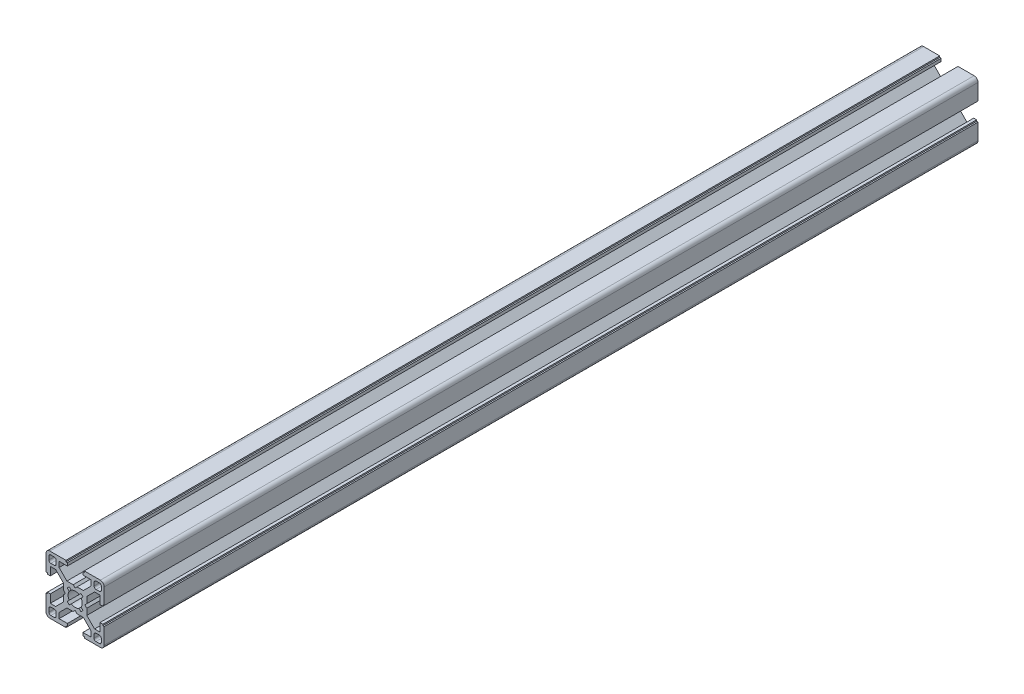
from build123d import *

# Parameters (mm, degrees)
ESTRUSIONE_ESTRUSIONE2_DEPTH = 450


with BuildPart() as part:
    # Schizzo1 → Estrusione-Estrusione2 (new body)
    with BuildSketch(Plane.XY):
        with BuildLine():
            Line((-15, 13), (-15, 4.7))
            Line((-15, 4.7), (-14.3, 4.7))
            Line((-14.3, 4.7), (-14.3, 4))
            Line((-14.3, 4), (-12.8, 4))
            Line((-12.8, 4), (-12.8, 8.25))
            Line((-12.8, 8.25), (-10.017766953, 8.25))
            Line((-10.017766953, 8.25), (-6, 4.232233047))
            Line((-6, 4.232233047), (-6, 1))
            Line((-6, 1), (-5, 0))
            Line((-5, 0), (-6, -1))
            Line((-6, -1), (-6, -4.232233047))
            Line((-6, -4.232233047), (-10.017766953, -8.25))
            Line((-10.017766953, -8.25), (-12.8, -8.25))
            Line((-12.8, -8.25), (-12.8, -4))
            Line((-12.8, -4), (-14.3, -4))
            Line((-14.3, -4), (-14.3, -4.7))
            Line((-14.3, -4.7), (-15, -4.7))
            Line((-15, -4.7), (-15, -13))
            ThreePointArc((-15, -13), (-14.414213562, -14.414213562), (-13, -15))
            Line((-13, -15), (-4.7, -15))
            Line((-4.7, -15), (-4.7, -14.3))
            Line((-4.7, -14.3), (-4, -14.3))
            Line((-4, -14.3), (-4, -12.8))
            Line((-4, -12.8), (-8.25, -12.8))
            Line((-8.25, -12.8), (-8.25, -10.017766953))
            Line((-8.25, -10.017766953), (-4.232233047, -6))
            Line((-4.232233047, -6), (-1, -6))
            Line((-1, -6), (0, -5))
            Line((0, -5), (1, -6))
            Line((1, -6), (4.232233047, -6))
            Line((4.232233047, -6), (8.25, -10.017766953))
            Line((8.25, -10.017766953), (8.25, -12.8))
            Line((8.25, -12.8), (4, -12.8))
            Line((4, -12.8), (4, -14.3))
            Line((4, -14.3), (4.7, -14.3))
            Line((4.7, -14.3), (4.7, -15))
            Line((4.7, -15), (13, -15))
            ThreePointArc((13, -15), (14.414213562, -14.414213562), (15, -13))
            Line((15, -13), (15, -4.7))
            Line((15, -4.7), (14.3, -4.7))
            Line((14.3, -4.7), (14.3, -4))
            Line((14.3, -4), (12.8, -4))
            Line((12.8, -4), (12.8, -8.25))
            Line((12.8, -8.25), (10.017766953, -8.25))
            Line((10.017766953, -8.25), (6, -4.232233047))
            Line((6, -4.232233047), (6, -1))
            Line((6, -1), (5, 0))
            Line((5, 0), (6, 1))
            Line((6, 1), (6, 4.232233047))
            Line((6, 4.232233047), (10.017766953, 8.25))
            Line((10.017766953, 8.25), (12.8, 8.25))
            Line((12.8, 8.25), (12.8, 4))
            Line((12.8, 4), (14.3, 4))
            Line((14.3, 4), (14.3, 4.7))
            Line((14.3, 4.7), (15, 4.7))
            Line((15, 4.7), (15, 13))
            ThreePointArc((15, 13), (14.414213562, 14.414213562), (13, 15))
            Line((13, 15), (4.7, 15))
            Line((4.7, 15), (4.7, 14.3))
            Line((4.7, 14.3), (4, 14.3))
            Line((4, 14.3), (4, 12.8))
            Line((4, 12.8), (8.25, 12.8))
            Line((8.25, 12.8), (8.25, 10.017766953))
            Line((8.25, 10.017766953), (4.232233047, 6))
            Line((4.232233047, 6), (1, 6))
            Line((1, 6), (0, 5))
            Line((0, 5), (-1, 6))
            Line((-1, 6), (-4.232233047, 6))
            Line((-4.232233047, 6), (-8.25, 10.017766953))
            Line((-8.25, 10.017766953), (-8.25, 12.8))
            Line((-8.25, 12.8), (-4, 12.8))
            Line((-4, 12.8), (-4, 14.3))
            Line((-4, 14.3), (-4.7, 14.3))
            Line((-4.7, 14.3), (-4.7, 15))
            Line((-4.7, 15), (-13, 15))
            ThreePointArc((-13, 15), (-14.414213562, 14.414213562), (-15, 13))
        make_face()
        with BuildLine():
            Line((13.5, 10.75), (13.5, 12.5))
            ThreePointArc((13.5, 12.5), (13.207106781, 13.207106781), (12.5, 13.5))
            Line((12.5, 13.5), (10.75, 13.5))
            ThreePointArc((10.75, 13.5), (10.042893219, 13.207106781), (9.75, 12.5))
            Line((9.75, 12.5), (9.75, 10.75))
            ThreePointArc((9.75, 10.75), (10.042893219, 10.042893219), (10.75, 9.75))
            Line((10.75, 9.75), (12.5, 9.75))
            ThreePointArc((12.5, 9.75), (13.207106781, 10.042893219), (13.5, 10.75))
        make_face(mode=Mode.SUBTRACT)
        with BuildLine():
            Line((10.75, -13.5), (12.5, -13.5))
            ThreePointArc((12.5, -13.5), (13.207106781, -13.207106781), (13.5, -12.5))
            Line((13.5, -12.5), (13.5, -10.75))
            ThreePointArc((13.5, -10.75), (13.207106781, -10.042893219), (12.5, -9.75))
            Line((12.5, -9.75), (10.75, -9.75))
            ThreePointArc((10.75, -9.75), (10.042893219, -10.042893219), (9.75, -10.75))
            Line((9.75, -10.75), (9.75, -12.5))
            ThreePointArc((9.75, -12.5), (10.042893219, -13.207106781), (10.75, -13.5))
        make_face(mode=Mode.SUBTRACT)
        with BuildLine():
            Line((-13.5, -10.75), (-13.5, -12.5))
            ThreePointArc((-13.5, -12.5), (-13.207106781, -13.207106781), (-12.5, -13.5))
            Line((-12.5, -13.5), (-10.75, -13.5))
            ThreePointArc((-10.75, -13.5), (-10.042893219, -13.207106781), (-9.75, -12.5))
            Line((-9.75, -12.5), (-9.75, -10.75))
            ThreePointArc((-9.75, -10.75), (-10.042893219, -10.042893219), (-10.75, -9.75))
            Line((-10.75, -9.75), (-12.5, -9.75))
            ThreePointArc((-12.5, -9.75), (-13.207106781, -10.042893219), (-13.5, -10.75))
        make_face(mode=Mode.SUBTRACT)
        with BuildLine():
            Line((1.995536102, 3.056196274), (3.00520382, 4.065863992))
            Line((3.00520382, 4.065863992), (4.065863992, 3.00520382))
            Line((4.065863992, 3.00520382), (3.056196274, 1.995536102))
            ThreePointArc((3.056196274, 1.995536102), (3.498400806, 1.041005187), (3.65, 0))
            ThreePointArc((3.65, 0), (3.498400806, -1.041005187), (3.056196274, -1.995536102))
            Line((3.056196274, -1.995536102), (4.065863992, -3.00520382))
            Line((4.065863992, -3.00520382), (3.00520382, -4.065863992))
            Line((3.00520382, -4.065863992), (1.995536102, -3.056196274))
            ThreePointArc((1.995536102, -3.056196274), (1.041005187, -3.498400806), (0, -3.65))
            ThreePointArc((0, -3.65), (-1.041005187, -3.498400806), (-1.995536102, -3.056196274))
            Line((-1.995536102, -3.056196274), (-3.00520382, -4.065863992))
            Line((-3.00520382, -4.065863992), (-4.065863992, -3.00520382))
            Line((-4.065863992, -3.00520382), (-3.056196274, -1.995536102))
            ThreePointArc((-3.056196274, -1.995536102), (-3.498400806, -1.041005187), (-3.65, 0))
            ThreePointArc((-3.65, 0), (-3.498400806, 1.041005187), (-3.056196274, 1.995536102))
            Line((-3.056196274, 1.995536102), (-4.065863992, 3.00520382))
            Line((-4.065863992, 3.00520382), (-3.00520382, 4.065863992))
            Line((-3.00520382, 4.065863992), (-1.995536102, 3.056196274))
            ThreePointArc((-1.995536102, 3.056196274), (-1.041005187, 3.498400806), (0, 3.65))
            ThreePointArc((0, 3.65), (1.041005187, 3.498400806), (1.995536102, 3.056196274))
        make_face(mode=Mode.SUBTRACT)
        with BuildLine():
            Line((-10.75, 9.75), (-12.5, 9.75))
            ThreePointArc((-12.5, 9.75), (-13.207106781, 10.042893219), (-13.5, 10.75))
            Line((-13.5, 10.75), (-13.5, 12.5))
            ThreePointArc((-13.5, 12.5), (-13.207106781, 13.207106781), (-12.5, 13.5))
            Line((-12.5, 13.5), (-10.75, 13.5))
            ThreePointArc((-10.75, 13.5), (-10.042893219, 13.207106781), (-9.75, 12.5))
            Line((-9.75, 12.5), (-9.75, 10.75))
            ThreePointArc((-9.75, 10.75), (-10.042893219, 10.042893219), (-10.75, 9.75))
        make_face(mode=Mode.SUBTRACT)
    extrude(amount=ESTRUSIONE_ESTRUSIONE2_DEPTH)


solid = part.part
